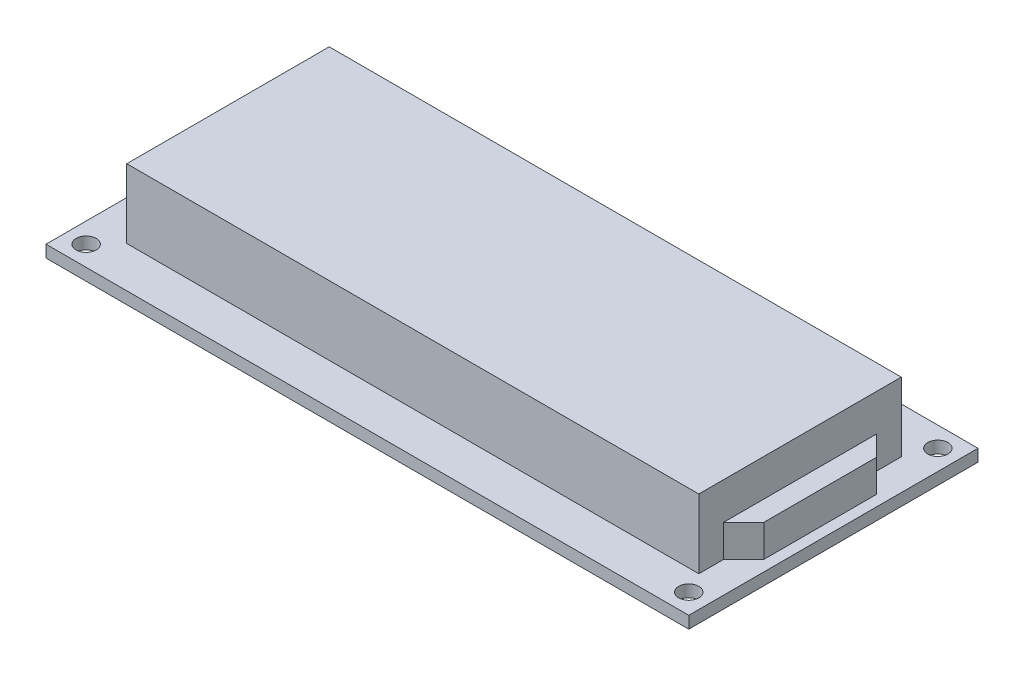
from build123d import *

# Parameters (mm, degrees)
SCHIZZO1_W                   = 80
SCHIZZO1_H                   = 36
ESTRUSIONE_ESTRUSIONE1_DEPTH = 1.5
SCHIZZO2_R                   = 1.25
TAGLIO_ESTRUSIONE1_DEPTH     = 1.5
SCHIZZO3_W                   = 71.2
SCHIZZO3_H                   = 25.2
ESTRUSIONE_ESTRUSIONE2_DEPTH = 8.6
ESTRUSIONE_ESTRUSIONE3_DEPTH = 4
SCHIZZO4_W                   = 41
SCHIZZO4_H                   = 2.54
ESTRUSIONE_ESTRUSIONE4_DEPTH = 18


with BuildPart() as part:
    # Schizzo1 → Estrusione-Estrusione1 (new body)
    with BuildSketch(Plane(origin=(0, 0, 0), x_dir=(1, 0, 0), z_dir=(0, 1, 0))):
        Rectangle(SCHIZZO1_W, SCHIZZO1_H)
    extrude(amount=ESTRUSIONE_ESTRUSIONE1_DEPTH)

    # Schizzo2 → Taglio-Estrusione1 (cut)
    with BuildSketch(Plane(origin=(0, 1.5, 0), x_dir=(1, 0, 0), z_dir=(0, 1, 0))):
        with Locations((-37.5, 15.5)):
            Circle(SCHIZZO2_R)
        with Locations((37.5, 15.5)):
            Circle(SCHIZZO2_R)
        with Locations((-37.5, -15.5)):
            Circle(SCHIZZO2_R)
        with Locations((37.5, -15.5)):
            Circle(SCHIZZO2_R)
    extrude(amount=-TAGLIO_ESTRUSIONE1_DEPTH, mode=Mode.SUBTRACT)

    # Schizzo3 → Estrusione-Estrusione2 (add)
    with BuildSketch(Plane(origin=(0, 1.5, 0), x_dir=(1, 0, 0), z_dir=(0, 1, 0))):
        with Locations((0.55, -0.3)):
            Rectangle(SCHIZZO3_W, SCHIZZO3_H)
    extrude(amount=ESTRUSIONE_ESTRUSIONE2_DEPTH)

    # Schizzo3_3 → Estrusione-Estrusione3 (add)
    with BuildSketch(Plane(origin=(0, 1.5, 0), x_dir=(1, 0, 0), z_dir=(0, 1, 0))):
        Polygon((38.65, 6.7), (36.15, 9.2), (36.15, -9.8), (38.65, -7.3), align=None)
    extrude(amount=ESTRUSIONE_ESTRUSIONE3_DEPTH)

    # Schizzo4 → Estrusione-Estrusione4 (add)
    with BuildSketch(Plane.XZ):
        with Locations((-12.5, -16.23)):
            Rectangle(SCHIZZO4_W, SCHIZZO4_H)
    extrude(amount=ESTRUSIONE_ESTRUSIONE4_DEPTH)


solid = part.part
